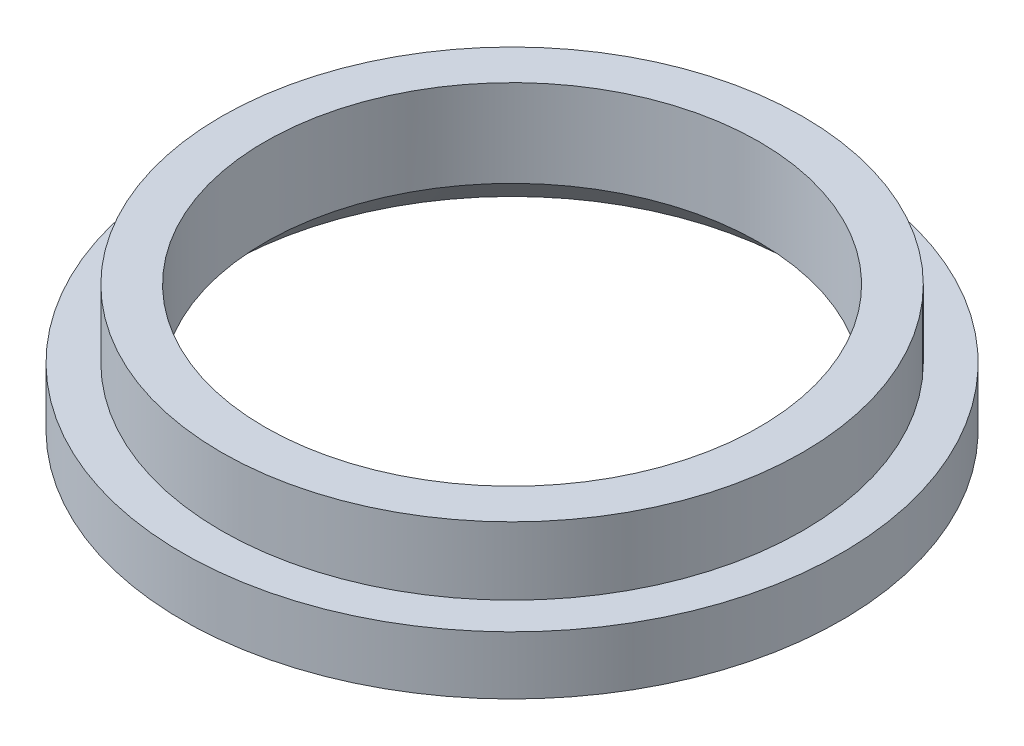
from build123d import *

# Parameters (mm, degrees)
SKETCH_1_R      = 15
SKETCH_1_R_2    = 12.75
EXTRUDE_1_DEPTH = 3.5
SKETCH_2_R      = 17
SKETCH_2_R_2    = 12.75
EXTRUDE_2_DEPTH = 3
CHAMFER_1_SIZE  = 2


with BuildPart() as part:
    # 草图1 → 凸台-拉伸1 (new body)
    with BuildSketch(Plane(origin=(0, 0, 0), x_dir=(1, 0, 0), z_dir=(0, 1, 0))):
        Circle(SKETCH_1_R)
        Circle(SKETCH_1_R_2, mode=Mode.SUBTRACT)
    extrude(amount=EXTRUDE_1_DEPTH)

    # 草图2 → 凸台-拉伸2 (add)
    with BuildSketch(Plane(origin=(0, 0, 0), x_dir=(-1, 0, 0), z_dir=(0, -1, 0))):
        Circle(SKETCH_2_R)
        Circle(SKETCH_2_R_2, mode=Mode.SUBTRACT)
    extrude(amount=EXTRUDE_2_DEPTH)

    # 倒角1
    chamfer_1_edges = [part.edges().sort_by_distance(p)[0] for p in [
        (12.75, -3, 0),
    ]]
    chamfer(chamfer_1_edges, length=CHAMFER_1_SIZE)


solid = part.part
